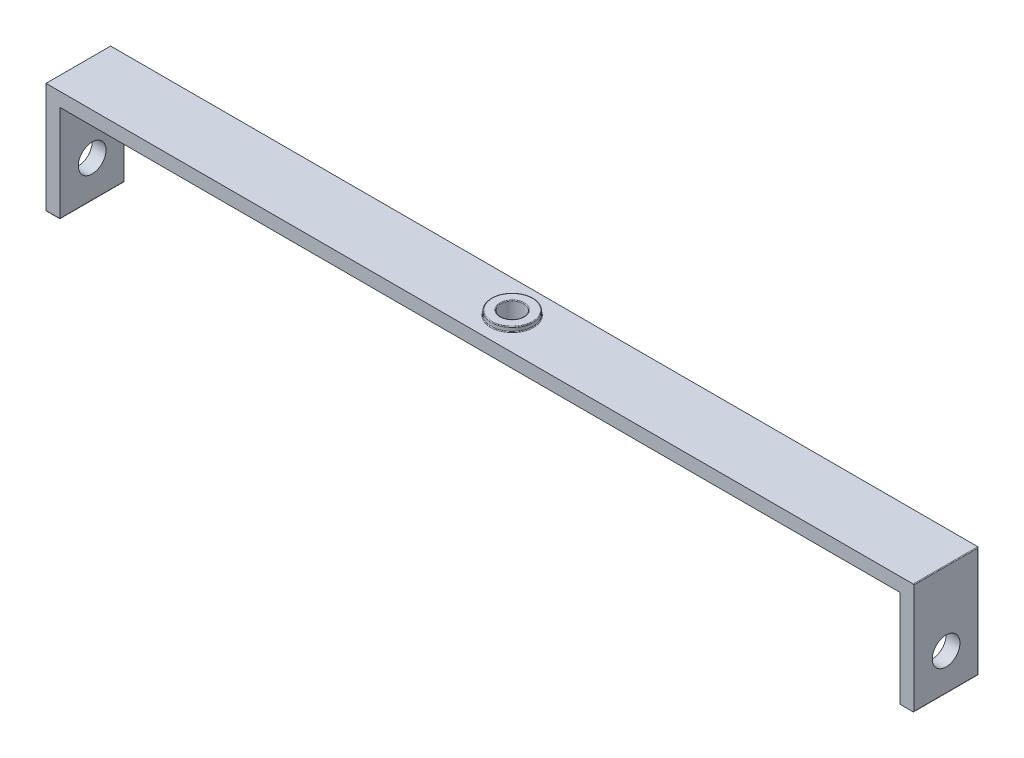
from build123d import *

# Parameters (mm, degrees)
BOSS_EXTRUDE1_DEPTH     = 3.5
SKETCH2_R               = 1.25
CUT_EXTRUDE1_DEPTH      = 13
SKETCH3_R               = 2.25
SKETCH3_R_2             = 1.25
BOSS_EXTRUDE2_DEPTH     = 0.5
SKETCH4_R               = 1.5
CUT_EXTRUDE2_DEPTH      = 48
CUT_EXTRUDE2_DEPTH_BACK = 48
FILLET1_R               = 0.075


with BuildPart() as part:
    # Sketch1 → Boss-Extrude1 (new body, symmetric)
    with BuildSketch(Plane.XY):
        Polygon((-47, 0), (47, 0), (47, -12), (45.5, -12), (45.5, -1.5), (-45.5, -1.5), (-45.5, -12), (-47, -12), align=None)
    extrude(amount=BOSS_EXTRUDE1_DEPTH, both=True)

    # Sketch2 → Cut-Extrude1 (cut, through all)
    with BuildSketch(Plane(origin=(0, 0, 0), x_dir=(1, 0, 0), z_dir=(0, 1, 0))):
        Circle(SKETCH2_R)
    extrude(amount=-CUT_EXTRUDE1_DEPTH, mode=Mode.SUBTRACT)

    # Sketch3 → Boss-Extrude2 (add)
    with BuildSketch(Plane(origin=(0, 0, 0), x_dir=(1, 0, 0), z_dir=(0, 1, 0))):
        Circle(SKETCH3_R)
        Circle(SKETCH3_R_2, mode=Mode.SUBTRACT)
    extrude(amount=BOSS_EXTRUDE2_DEPTH)

    # Sketch4 → Cut-Extrude2 (cut, two sides)
    with BuildSketch(Plane(origin=(0, 0, 0), x_dir=(0, 0, -1), z_dir=(1, 0, 0))) as cut_extrude2_sk:
        with Locations((0, -8)):
            Circle(SKETCH4_R)
    extrude(amount=CUT_EXTRUDE2_DEPTH, mode=Mode.SUBTRACT)
    extrude(cut_extrude2_sk.sketch, amount=-CUT_EXTRUDE2_DEPTH_BACK, mode=Mode.SUBTRACT)

    # Fillet1
    fillet1_edges = [part.edges().sort_by_distance(p)[0] for p in [
        (-45.5, -6.75, -3.5),
        (0, -1.5, -3.5),
        (-2.25, 0, 0),
        (47, -12, 0),
        (47, 0, 0),
        (-47, -12, 0),
        (-45.5, -12, 0),
        (-45.5, -1.5, 0),
        (45.5, -1.5, 0),
        (45.5, -12, 0),
        (-46.25, -12, 3.5),
        (45.5, -6.75, -3.5),
        (-46.25, -12, -3.5),
        (47, -6, -3.5),
        (46.25, -12, -3.5),
        (-1.25, -1.5, 0),
        (-2.25, 0.5, 0),
        (-1.25, 0.5, 0),
    ]]
    fillet(fillet1_edges, radius=FILLET1_R)


solid = part.part
